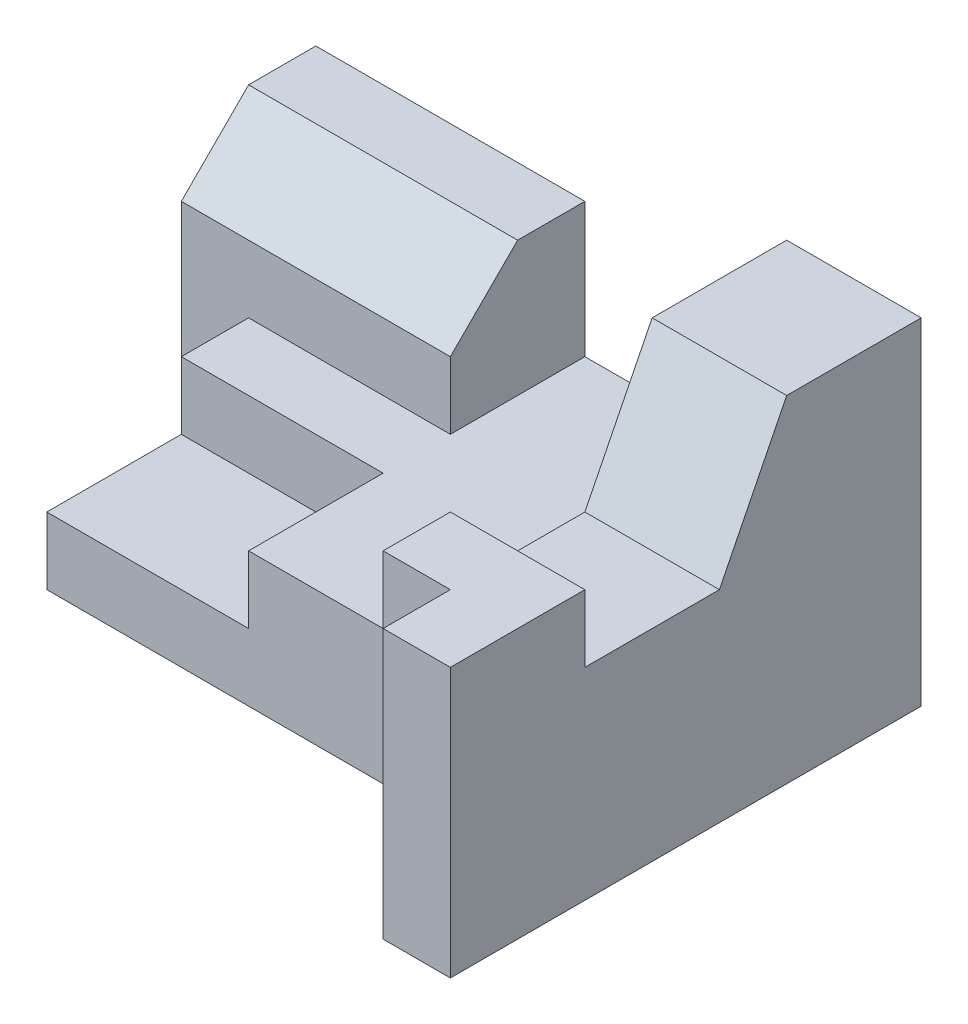
from build123d import *

# Parameters (mm, degrees)
SKETCH1_W           = 6
SKETCH1_H           = 5
BOSS_EXTRUDE1_DEPTH = 2
SKETCH2_W           = 4
SKETCH2_H           = 2
BOSS_EXTRUDE2_DEPTH = 4
CHAMFER1_SIZE       = 1
BOSS_EXTRUDE3_DEPTH = 5
CUT_EXTRUDE1_DEPTH  = 5
SKETCH6_W           = 3
SKETCH6_H           = 2
CUT_EXTRUDE2_DEPTH  = 1


with BuildPart() as part:
    # Sketch1 → Boss-Extrude1 (new body)
    with BuildSketch(Plane(origin=(0, 0, 0), x_dir=(1, 0, 0), z_dir=(0, 1, 0))):
        Rectangle(SKETCH1_W, SKETCH1_H)
    extrude(amount=BOSS_EXTRUDE1_DEPTH)

    # Sketch2 → Boss-Extrude2 (add)
    with BuildSketch(Plane(origin=(0, 0, 0), x_dir=(1, 0, 0), z_dir=(0, 1, 0))):
        with Locations((-2, 1.5)):
            Rectangle(SKETCH2_W, SKETCH2_H)
    extrude(amount=BOSS_EXTRUDE2_DEPTH)

    # Chamfer1
    chamfer1_edges = [part.edges().sort_by_distance(p)[0] for p in [
        (-2, 4, -0.5),
    ]]
    chamfer(chamfer1_edges, length=CHAMFER1_SIZE)

    # Sketch3 → Boss-Extrude3 (add)
    with BuildSketch(Plane(origin=(0, 0, 0), x_dir=(1, 0, 0), z_dir=(0, 1, 0))):
        Polygon((3, 2.5), (5, 2.5), (5, -4.5), (4, -4.5), (4, -3.5), (3, -3.5), align=None)
    extrude(amount=BOSS_EXTRUDE3_DEPTH)

    # Sketch5 → Cut-Extrude1 (cut)
    with BuildSketch(Plane.ZY.offset(-3)):
        Polygon((-0.5, 5), (0.5, 3), (2.5, 3), (2.5, 4), (5.863314104, 4), (5.863314104, 5.536679496), align=None)
    extrude(amount=-CUT_EXTRUDE1_DEPTH, mode=Mode.SUBTRACT)

    # Sketch6 → Cut-Extrude2 (cut)
    with BuildSketch(Plane(origin=(0, 2, 0), x_dir=(1, 0, 0), z_dir=(0, 1, 0))):
        with Locations((-1.5, -1.5)):
            Rectangle(SKETCH6_W, SKETCH6_H)
    extrude(amount=-CUT_EXTRUDE2_DEPTH, mode=Mode.SUBTRACT)


solid = part.part
